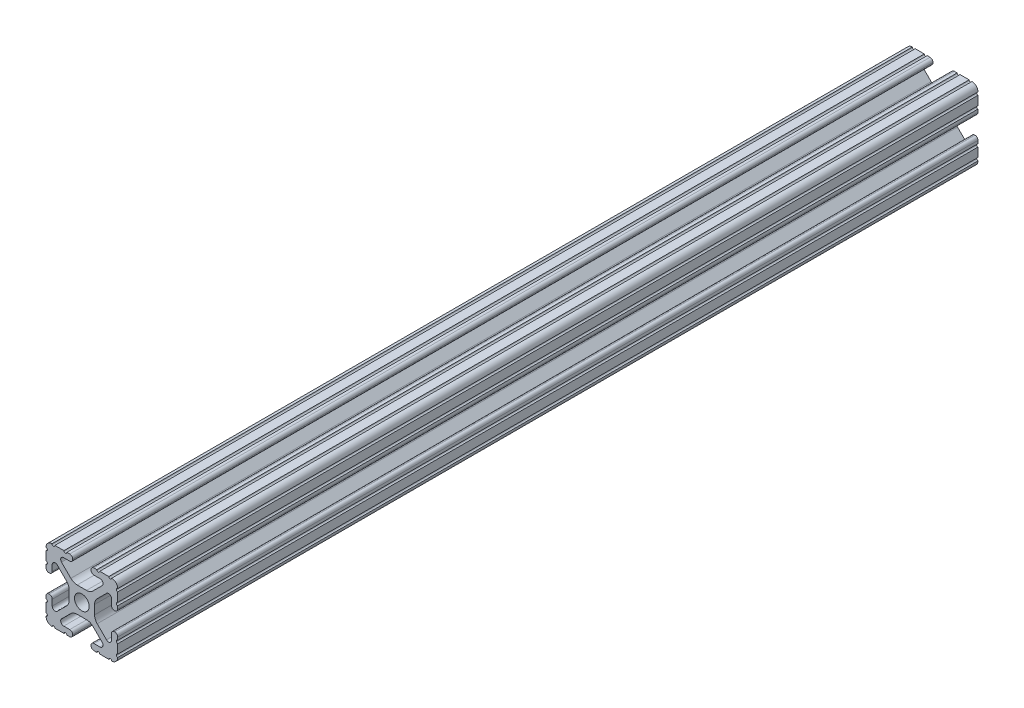
from build123d import *

# Parameters (mm, degrees)
SKETCH1_R           = 2.6035
BOSS_EXTRUDE1_DEPTH = 152.4


with BuildPart() as part:
    # Sketch1 → Boss-Extrude1 (new body, symmetric)
    with BuildSketch(Plane.XY):
        with BuildLine():
            Line((-7.179650497, -8.645192506), (-3.952270251, -5.423690499))
            ThreePointArc((-3.952270251, -5.423690499), (-2.922936451, -4.736929036), (-1.709253557, -4.4958))
            Line((-1.709253557, -4.4958), (1.709253557, -4.4958))
            ThreePointArc((1.709253557, -4.4958), (2.922936451, -4.736929036), (3.952270251, -5.423690499))
            Line((3.952270251, -5.423690499), (7.179650497, -8.645192506))
            ThreePointArc((7.179650497, -8.645192506), (7.41473083, -9.822813117), (6.416408329, -10.4902))
            Line((6.416408329, -10.4902), (4.287512407, -10.4902))
            ThreePointArc((4.287512407, -10.4902), (3.54574862, -10.79744862), (3.2385, -11.539212407))
            Line((3.2385, -11.539212407), (3.2385, -11.650987593))
            ThreePointArc((3.2385, -11.650987593), (3.54574862, -12.39275138), (4.287512407, -12.7))
            Line((4.287512407, -12.7), (5.317126718, -12.7))
            ThreePointArc((5.317126718, -12.7), (5.825126718, -12.192), (6.333126718, -12.7))
            Line((6.333126718, -12.7), (9.550443118, -12.7))
            ThreePointArc((9.550443118, -12.7), (10.058366869, -12.192000006), (10.566443095, -12.699847501))
            ThreePointArc((10.566443095, -12.699847501), (12.082537762, -12.08250727), (12.699846982, -10.566399977))
            ThreePointArc((12.699846982, -10.566399977), (12.192000006, -10.058323491), (12.7, -9.5504))
            Line((12.7, -9.5504), (12.7, -6.3330836))
            ThreePointArc((12.7, -6.3330836), (12.192, -5.8250836), (12.7, -5.3170836))
            Line((12.7, -5.3170836), (12.7, -4.287469289))
            ThreePointArc((12.7, -4.287469289), (12.39275138, -3.545705502), (11.650987593, -3.238456882))
            Line((11.650987593, -3.238456882), (11.539212407, -3.238456882))
            ThreePointArc((11.539212407, -3.238456882), (10.79744862, -3.545705502), (10.4902, -4.287469289))
            Line((10.4902, -4.287469289), (10.4902, -6.402089023))
            ThreePointArc((10.4902, -6.402089023), (9.856505071, -7.351067942), (8.737131347, -7.129408934))
            Line((8.737131347, -7.129408934), (5.441005833, -3.840816462))
            ThreePointArc((5.441005833, -3.840816462), (4.750877967, -2.809883091), (4.5085, -1.593185507))
            Line((4.5085, -1.593185507), (4.5085, 1.593185507))
            ThreePointArc((4.5085, 1.593185507), (4.750877967, 2.809883091), (5.441005833, 3.840816462))
            Line((5.441005833, 3.840816462), (8.737131347, 7.129408934))
            ThreePointArc((8.737131347, 7.129408934), (9.856505071, 7.351067942), (10.4902, 6.402089023))
            Line((10.4902, 6.402089023), (10.4902, 4.287469289))
            ThreePointArc((10.4902, 4.287469289), (10.79744862, 3.545705502), (11.539212407, 3.238456882))
            Line((11.539212407, 3.238456882), (11.650987593, 3.238456882))
            ThreePointArc((11.650987593, 3.238456882), (12.39275138, 3.545705502), (12.7, 4.287469289))
            Line((12.7, 4.287469289), (12.7, 5.3170836))
            ThreePointArc((12.7, 5.3170836), (12.192, 5.8250836), (12.7, 6.3330836))
            Line((12.7, 6.3330836), (12.7, 9.5504))
            ThreePointArc((12.7, 9.5504), (12.192000006, 10.058323491), (12.699846982, 10.566399977))
            ThreePointArc((12.699846982, 10.566399977), (12.082537762, 12.08250727), (10.566443095, 12.699847501))
            ThreePointArc((10.566443095, 12.699847501), (10.058366869, 12.192000006), (9.550443118, 12.7))
            Line((9.550443118, 12.7), (6.333126718, 12.7))
            ThreePointArc((6.333126718, 12.7), (5.825126718, 12.192), (5.317126718, 12.7))
            Line((5.317126718, 12.7), (4.287512407, 12.7))
            ThreePointArc((4.287512407, 12.7), (3.54574862, 12.39275138), (3.2385, 11.650987593))
            Line((3.2385, 11.650987593), (3.2385, 11.539212407))
            ThreePointArc((3.2385, 11.539212407), (3.54574862, 10.79744862), (4.287512407, 10.4902))
            Line((4.287512407, 10.4902), (6.476788598, 10.4902))
            ThreePointArc((6.476788598, 10.4902), (7.432222385, 9.85140422), (7.207036008, 8.724370562))
            Line((7.207036008, 8.724370562), (3.898272566, 5.423169045))
            ThreePointArc((3.898272566, 5.423169045), (2.869120213, 4.736787962), (1.655778399, 4.4958))
            Line((1.655778399, 4.4958), (-1.655778399, 4.4958))
            ThreePointArc((-1.655778399, 4.4958), (-2.869120213, 4.736787962), (-3.898272566, 5.423169045))
            Line((-3.898272566, 5.423169045), (-7.207036008, 8.724370562))
            ThreePointArc((-7.207036008, 8.724370562), (-7.432222385, 9.85140422), (-6.476788598, 10.4902))
            Line((-6.476788598, 10.4902), (-4.287512407, 10.4902))
            ThreePointArc((-4.287512407, 10.4902), (-3.54574862, 10.79744862), (-3.2385, 11.539212407))
            Line((-3.2385, 11.539212407), (-3.2385, 11.650987593))
            ThreePointArc((-3.2385, 11.650987593), (-3.54574862, 12.39275138), (-4.287512407, 12.7))
            Line((-4.287512407, 12.7), (-5.317126718, 12.7))
            ThreePointArc((-5.317126718, 12.7), (-5.825126718, 12.192), (-6.333126718, 12.7))
            Line((-6.333126718, 12.7), (-9.550443118, 12.7))
            ThreePointArc((-9.550443118, 12.7), (-10.058366869, 12.192000006), (-10.566443095, 12.699847501))
            ThreePointArc((-10.566443095, 12.699847501), (-12.082537762, 12.08250727), (-12.699846982, 10.566399977))
            ThreePointArc((-12.699846982, 10.566399977), (-12.192000006, 10.058323491), (-12.7, 9.5504))
            Line((-12.7, 9.5504), (-12.7, 6.3330836))
            ThreePointArc((-12.7, 6.3330836), (-12.192, 5.8250836), (-12.7, 5.3170836))
            Line((-12.7, 5.3170836), (-12.7, 4.287469289))
            ThreePointArc((-12.7, 4.287469289), (-12.39275138, 3.545705502), (-11.650987593, 3.238456882))
            Line((-11.650987593, 3.238456882), (-11.539212407, 3.238456882))
            ThreePointArc((-11.539212407, 3.238456882), (-10.79744862, 3.545705502), (-10.4902, 4.287469289))
            Line((-10.4902, 4.287469289), (-10.4902, 6.402089023))
            ThreePointArc((-10.4902, 6.402089023), (-9.856505071, 7.351067942), (-8.737131347, 7.129408934))
            Line((-8.737131347, 7.129408934), (-5.441005833, 3.840816462))
            ThreePointArc((-5.441005833, 3.840816462), (-4.750877967, 2.809883091), (-4.5085, 1.593185507))
            Line((-4.5085, 1.593185507), (-4.5085, -1.593185507))
            ThreePointArc((-4.5085, -1.593185507), (-4.750877967, -2.809883091), (-5.441005833, -3.840816462))
            Line((-5.441005833, -3.840816462), (-8.737131347, -7.129408934))
            ThreePointArc((-8.737131347, -7.129408934), (-9.856505071, -7.351067942), (-10.4902, -6.402089023))
            Line((-10.4902, -6.402089023), (-10.4902, -4.287469289))
            ThreePointArc((-10.4902, -4.287469289), (-10.79744862, -3.545705502), (-11.539212407, -3.238456882))
            Line((-11.539212407, -3.238456882), (-11.650987593, -3.238456882))
            ThreePointArc((-11.650987593, -3.238456882), (-12.39275138, -3.545705502), (-12.7, -4.287469289))
            Line((-12.7, -4.287469289), (-12.7, -5.3170836))
            ThreePointArc((-12.7, -5.3170836), (-12.192, -5.8250836), (-12.7, -6.3330836))
            Line((-12.7, -6.3330836), (-12.7, -9.5504))
            ThreePointArc((-12.7, -9.5504), (-12.192000006, -10.058323491), (-12.699846982, -10.566399977))
            ThreePointArc((-12.699846982, -10.566399977), (-12.082537762, -12.08250727), (-10.566443095, -12.699847501))
            ThreePointArc((-10.566443095, -12.699847501), (-10.058366869, -12.192000006), (-9.550443118, -12.7))
            Line((-9.550443118, -12.7), (-6.333126718, -12.7))
            ThreePointArc((-6.333126718, -12.7), (-5.825126718, -12.192), (-5.317126718, -12.7))
            Line((-5.317126718, -12.7), (-4.287512407, -12.7))
            ThreePointArc((-4.287512407, -12.7), (-3.54574862, -12.39275138), (-3.2385, -11.650987593))
            Line((-3.2385, -11.650987593), (-3.2385, -11.539212407))
            ThreePointArc((-3.2385, -11.539212407), (-3.54574862, -10.79744862), (-4.287512407, -10.4902))
            Line((-4.287512407, -10.4902), (-6.416408329, -10.4902))
            ThreePointArc((-6.416408329, -10.4902), (-7.41473083, -9.822813117), (-7.179650497, -8.645192506))
        make_face()
        Circle(SKETCH1_R, mode=Mode.SUBTRACT)
    extrude(amount=BOSS_EXTRUDE1_DEPTH, both=True)


solid = part.part
